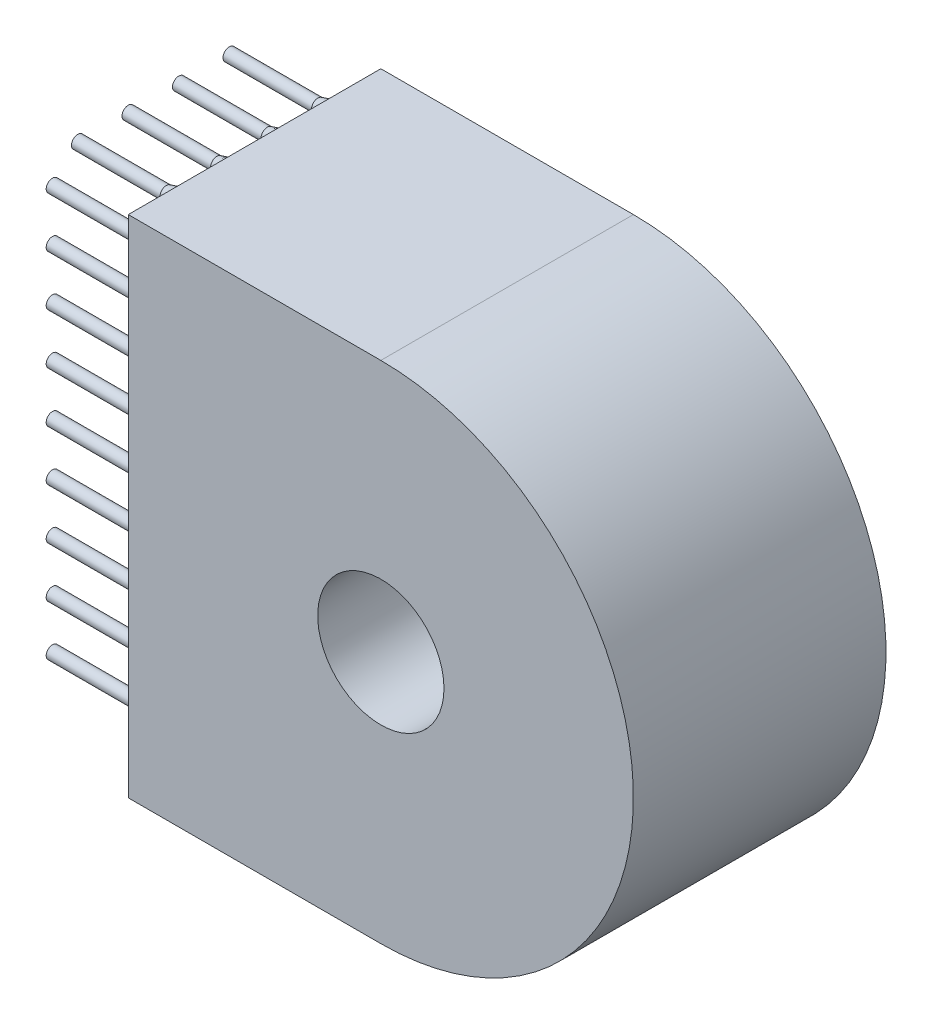
from build123d import *

# Parameters (mm, degrees)
SKETCH_1_R                          = 2.5
EXTRUDE_1_DEPTH                     = 10
SKETCH_2_R                          = 0.25
EXTRUDE_2_DEPTH                     = 5
CHAMFER_1_SIZE                      = 0.4
CHAMFER_1_SIZE2                     = 1.492820323
PATTERN_LINEAR_1_COUNT              = 4
PATTERN_LINEAR_1_PITCH              = 2
PATTERN_LINEAR_1_COUNT_DIR2         = 9
PATTERN_LINEAR_1_PITCH_DIR2         = 2
CHAMFER_1_OF_PATTERN_LINEAR_1_SIZE2 = 1.492820323
CHAMFER_1_OF_PATTERN_LINEAR_1_SIZE  = 0.4


with BuildPart() as part:
    # ｽｹｯﾁ1 → ﾎﾞｽ - 押し出し1 (new body)
    with BuildSketch(Plane.XY):
        with BuildLine():
            Line((0, 10), (-10, 10))
            Line((-10, 10), (-10, -10))
            Line((-10, -10), (0, -10))
            ThreePointArc((0, -10), (10, 0), (0, 10))
        make_face()
        Circle(SKETCH_1_R, mode=Mode.SUBTRACT)
    extrude(amount=EXTRUDE_1_DEPTH)

    # ｽｹｯﾁ2 → ﾎﾞｽ - 押し出し2 (add)
    with BuildSketch(Plane.ZY.offset(10)):
        with Locations((1, 8.5)):
            Circle(SKETCH_2_R)
        with Locations((2, 7.5)):
            Circle(SKETCH_2_R)
    extrude_2 = extrude(amount=EXTRUDE_2_DEPTH)

    # 面取り1
    chamfer_1_edges = [part.edges().sort_by_distance(p)[0] for p in [
        (-10, 8.5, 0.75),
        (-10, 7.5, 1.75),
    ]]
    chamfer_1_side = [part.faces().sort_by_distance(p)[0] for p in [
        (-10, -0.015738866, 5.006885754),
    ]]
    chamfer(chamfer_1_edges, length=CHAMFER_1_SIZE, length2=CHAMFER_1_SIZE2, reference=chamfer_1_side[0])

    # 直線ﾊﾟﾀｰﾝ1: Extrude 2 4 × 9
    with Locations(*[(0, -j * PATTERN_LINEAR_1_PITCH_DIR2, i * PATTERN_LINEAR_1_PITCH) for i in range(PATTERN_LINEAR_1_COUNT) for j in range(PATTERN_LINEAR_1_COUNT_DIR2) if (i, j) != (0, 0)]):
        add(extrude_2)

    # 面取り1 of 直線ﾊﾟﾀｰﾝ1
    chamfer_1_of_pattern_linear_1_edges = [part.edges().sort_by_distance(p)[0] for p in [
        (-10, 6.5, 0.75),
        (-10, 5.5, 1.75),
        (-10, 4.5, 0.75),
        (-10, 3.5, 1.75),
        (-10, 2.5, 0.75),
        (-10, 1.5, 1.75),
        (-10, 0.5, 0.75),
        (-10, -0.5, 1.75),
        (-10, -1.5, 0.75),
        (-10, -2.5, 1.75),
        (-10, -3.5, 0.75),
        (-10, -4.5, 1.75),
        (-10, -5.5, 0.75),
        (-10, -6.5, 1.75),
        (-10, -7.5, 0.75),
        (-10, -8.5, 1.75),
        (-10, 8.5, 2.75),
        (-10, 7.5, 3.75),
        (-10, 6.5, 2.75),
        (-10, 5.5, 3.75),
        (-10, 4.5, 2.75),
        (-10, 3.5, 3.75),
        (-10, 2.5, 2.75),
        (-10, 1.5, 3.75),
        (-10, 0.5, 2.75),
        (-10, -0.5, 3.75),
        (-10, -1.5, 2.75),
        (-10, -2.5, 3.75),
        (-10, -3.5, 2.75),
        (-10, -4.5, 3.75),
        (-10, -5.5, 2.75),
        (-10, -6.5, 3.75),
        (-10, -7.5, 2.75),
        (-10, -8.5, 3.75),
        (-10, 8.5, 4.75),
        (-10, 7.5, 5.75),
        (-10, 6.5, 4.75),
        (-10, 5.5, 5.75),
        (-10, 4.5, 4.75),
        (-10, 3.5, 5.75),
        (-10, 2.5, 4.75),
        (-10, 1.5, 5.75),
        (-10, 0.5, 4.75),
        (-10, -0.5, 5.75),
        (-10, -1.5, 4.75),
        (-10, -2.5, 5.75),
        (-10, -3.5, 4.75),
        (-10, -4.5, 5.75),
        (-10, -5.5, 4.75),
        (-10, -6.5, 5.75),
        (-10, -7.5, 4.75),
        (-10, -8.5, 5.75),
        (-10, 8.5, 6.75),
        (-10, 7.5, 7.75),
        (-10, 6.5, 6.75),
        (-10, 5.5, 7.75),
        (-10, 4.5, 6.75),
        (-10, 3.5, 7.75),
        (-10, 2.5, 6.75),
        (-10, 1.5, 7.75),
        (-10, 0.5, 6.75),
        (-10, -0.5, 7.75),
        (-10, -1.5, 6.75),
        (-10, -2.5, 7.75),
        (-10, -3.5, 6.75),
        (-10, -4.5, 7.75),
        (-10, -5.5, 6.75),
        (-10, -6.5, 7.75),
        (-10, -7.5, 6.75),
        (-10, -8.5, 7.75),
    ]]
    chamfer(chamfer_1_of_pattern_linear_1_edges, length=CHAMFER_1_OF_PATTERN_LINEAR_1_SIZE, length2=CHAMFER_1_OF_PATTERN_LINEAR_1_SIZE2)


solid = part.part
